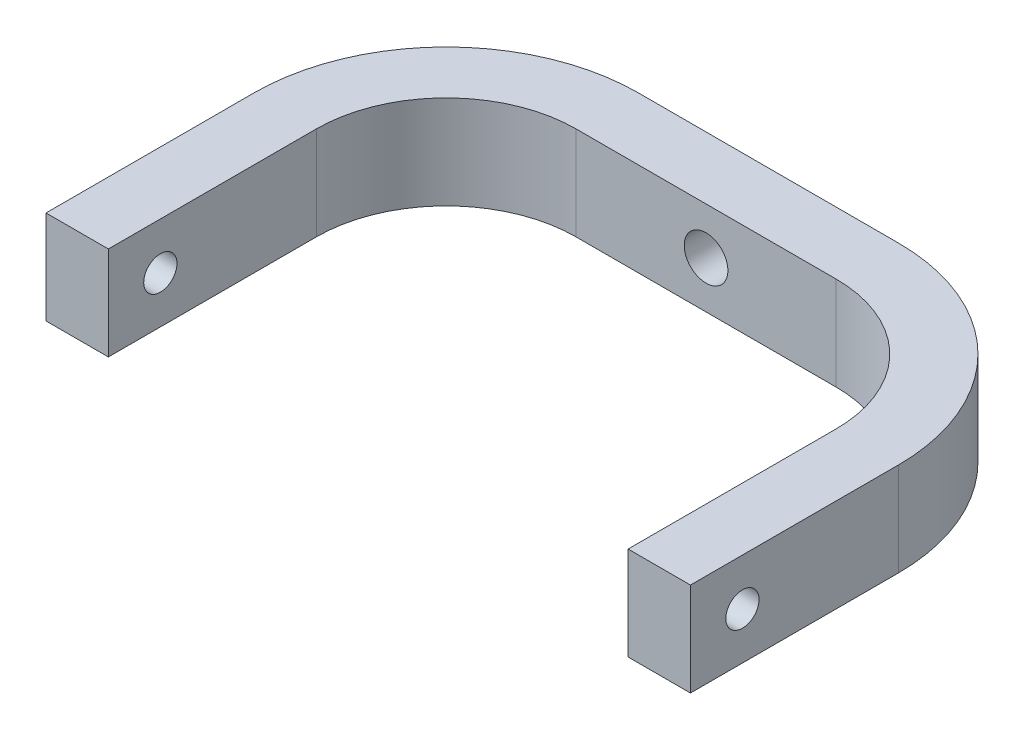
from build123d import *

# Parameters (mm, degrees)
BOSS_EXTRUDE1_DEPTH     = 18
SKETCH2_R               = 3.2
CUT_EXTRUDE1_DEPTH      = 150
CUT_EXTRUDE1_DEPTH_BACK = 40
SKETCH3_R               = 4.2
CUT_EXTRUDE2_DEPTH      = 40


with BuildPart() as part:
    # Sketch1 → Boss-Extrude1 (new body)
    with BuildSketch(Plane(origin=(0, 0, 0), x_dir=(1, 0, 0), z_dir=(0, 1, 0))):
        with BuildLine():
            Line((-70.033707865, -37.921348315), (-58.033707865, -37.921348315))
            Line((-58.033707865, -37.921348315), (-58.033707865, 2.078651685))
            ThreePointArc((-58.033707865, 2.078651685), (-50.711377395, 19.756321215), (-33.033707865, 27.078651685))
            Line((-33.033707865, 27.078651685), (-8.033707865, 27.078651685))
            Line((-8.033707865, 27.078651685), (-8.033707865, 39.078651685))
            Line((-8.033707865, 39.078651685), (-33.033707865, 39.078651685))
            ThreePointArc((-33.033707865, 39.078651685), (-59.196658769, 28.241602589), (-70.033707865, 2.078651685))
            Line((-70.033707865, 2.078651685), (-70.033707865, -37.921348315))
        make_face()
    boss_extrude1 = extrude(amount=BOSS_EXTRUDE1_DEPTH)

    # Mirror1: Boss-Extrude1 across plane
    add(boss_extrude1.mirror(Plane(origin=(-8.033707865, 18, -39.078651685), x_dir=(0, 0, 1), z_dir=(-1, 0, 0))))

    # Sketch2 → Cut-Extrude1 (cut, two sides)
    with BuildSketch(Plane(origin=(-58.033707865, 0, 0), x_dir=(0, 0, -1), z_dir=(1, 0, 0))) as cut_extrude1_sk:
        with Locations((-27.921348315, 9)):
            Circle(SKETCH2_R)
    extrude(amount=CUT_EXTRUDE1_DEPTH, mode=Mode.SUBTRACT)
    extrude(cut_extrude1_sk.sketch, amount=-CUT_EXTRUDE1_DEPTH_BACK, mode=Mode.SUBTRACT)

    # Sketch3 → Cut-Extrude2 (cut)
    with BuildSketch(Plane.XY.offset(-27.078651685)):
        with Locations((-8.033707865, 9)):
            Circle(SKETCH3_R)
    extrude(amount=-CUT_EXTRUDE2_DEPTH, mode=Mode.SUBTRACT)


solid = part.part
